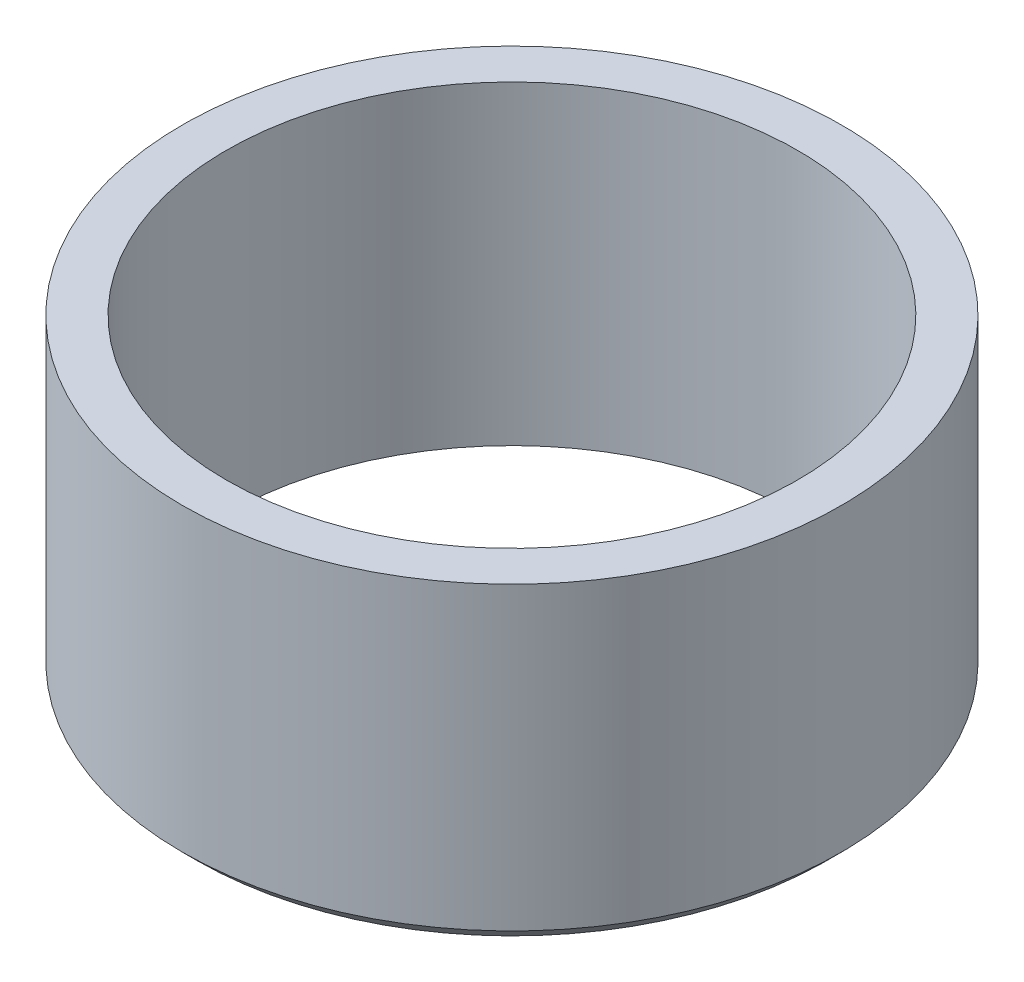
from build123d import *

# Parameters (mm, degrees)
SKETCH1_R           = 4.5
BOSS_EXTRUDE1_DEPTH = 4.3
SKETCH2_R           = 3.9
CUT_EXTRUDE1_DEPTH  = 5.3
CHAMFER1_SIZE       = 0.2


with BuildPart() as part:
    # Sketch1 → Boss-Extrude1 (new body)
    with BuildSketch(Plane(origin=(0, 0, 0), x_dir=(1, 0, 0), z_dir=(0, 1, 0))):
        Circle(SKETCH1_R)
    extrude(amount=BOSS_EXTRUDE1_DEPTH)

    # Sketch2 → Cut-Extrude1 (cut, through all)
    with BuildSketch(Plane(origin=(0, 4.3, 0), x_dir=(1, 0, 0), z_dir=(0, 1, 0))):
        Circle(SKETCH2_R)
    extrude(amount=-CUT_EXTRUDE1_DEPTH, mode=Mode.SUBTRACT)

    # Chamfer1
    chamfer1_edges = [part.edges().sort_by_distance(p)[0] for p in [
        (-4.5, 0, 0),
    ]]
    chamfer(chamfer1_edges, length=CHAMFER1_SIZE)


solid = part.part
